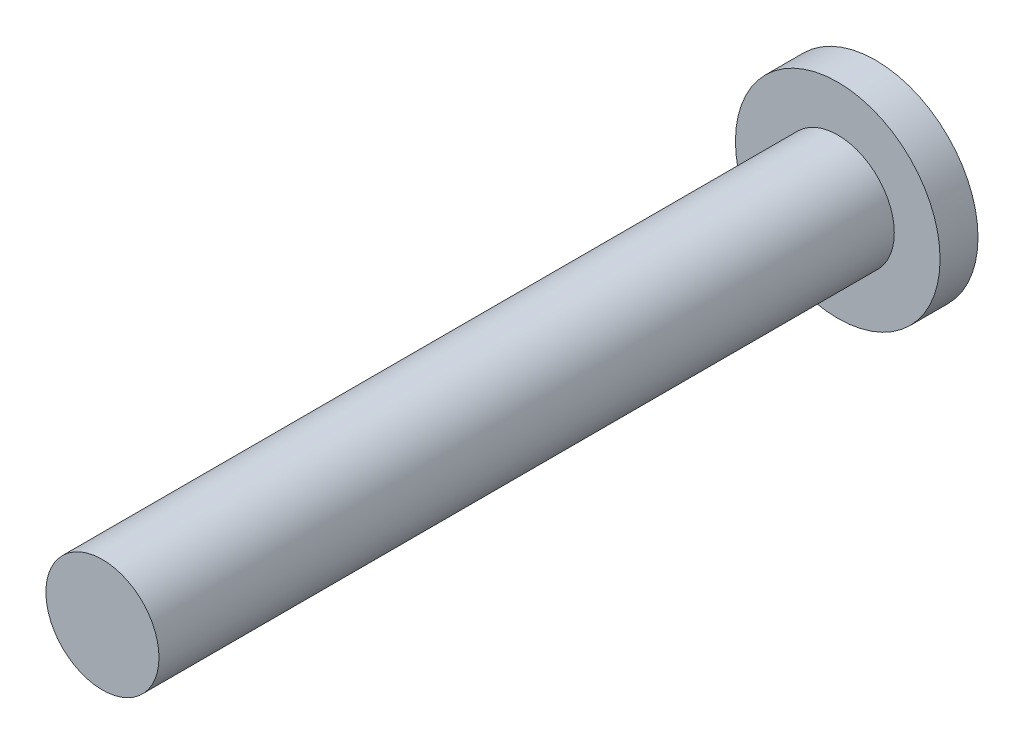
from build123d import *

# Parameters (mm, degrees)
SKETCH1_R           = 4.425
BOSS_EXTRUDE1_DEPTH = 1.64
SKETCH2_R           = 2.445
BOSS_EXTRUDE2_DEPTH = 31.8


with BuildPart() as part:
    # Sketch1 → Boss-Extrude1 (new body)
    with BuildSketch(Plane.XY):
        Circle(SKETCH1_R)
    extrude(amount=BOSS_EXTRUDE1_DEPTH)

    # Sketch2 → Boss-Extrude2 (add)
    with BuildSketch(Plane.XY.offset(1.64)):
        Circle(SKETCH2_R)
    extrude(amount=BOSS_EXTRUDE2_DEPTH)


solid = part.part
